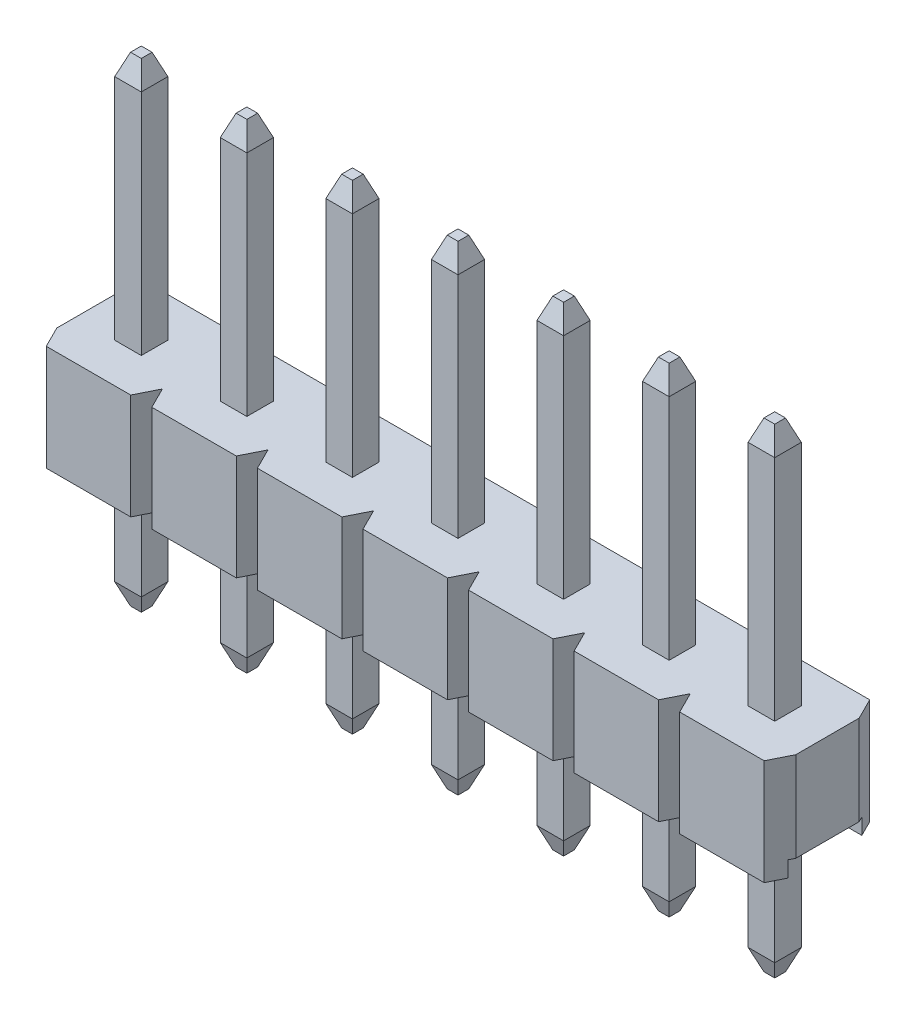
from build123d import *
from OCP.BRepFilletAPI import BRepFilletAPI_MakeChamfer

# Parameters (mm, degrees)
SKETCH1_W                     = 2.54
SKETCH1_H                     = 2.54
MAIN_BODY_DEPTH               = 2.54
SKETCH3_W                     = 1.778
SKETCH3_H                     = 0.381
CUT_EXTRUDE1_DEPTH            = 5.399409051
CUT_EXTRUDE2_DEPTH            = 5.399409051
BODY_PATTERN_COUNT            = 7
BODY_PATTERN_PITCH            = 2.54
PIN_START                     = -5.54
SKETCH2_W                     = 0.64
SKETCH2_H                     = 0.64
PIN_DEPTH                     = 11.54
CHAMFER1_SIZE                 = 0.508
CHAMFER1_SIZE2                = 0.1905
CHAMFER2_SIZE                 = 0.1905
CHAMFER2_SIZE2                = 0.508
PIN_PATTERN_COUNT             = 7
PIN_PATTERN_PITCH             = 2.54
CHAMFER1_OF_PIN_PATTERN_SIZE  = 0.508
CHAMFER1_OF_PIN_PATTERN_SIZE2 = 0.1905
CHAMFER2_OF_PIN_PATTERN_SIZE2 = 0.1905
CHAMFER2_OF_PIN_PATTERN_SIZE  = 0.508


with BuildPart() as part:
    # Sketch1 → Main Body (new body)
    with BuildSketch(Plane(origin=(0, 0, 0), x_dir=(1, 0, 0), z_dir=(0, 1, 0))):
        with Locations((1.27, 1.27)):
            Rectangle(SKETCH1_W, SKETCH1_H)
    main_body = extrude(amount=MAIN_BODY_DEPTH)

    # Sketch3 → Cut-Extrude1 (cut, through all)
    with BuildSketch(Plane.ZY):
        with Locations((-1.27, 0.1905)):
            Rectangle(SKETCH3_W, SKETCH3_H)
    cut_extrude1 = extrude(amount=-CUT_EXTRUDE1_DEPTH, mode=Mode.SUBTRACT)

    # Sketch4 → Cut-Extrude2 (cut, through all)
    with BuildSketch(Plane(origin=(0, 2.54, 0), x_dir=(1, 0, 0), z_dir=(0, 1, 0))):
        Polygon((0.254, 2.54), (0, 2.54), (0, 2.032), align=None)
        Polygon((2.54, 2.54), (2.286, 2.54), (2.54, 2.032), align=None)
        Polygon((0.254, 0), (0, 0.508), (0, 0), align=None)
        Polygon((2.54, 0), (2.286, 0), (2.54, 0.508), align=None)
    cut_extrude2 = extrude(amount=-CUT_EXTRUDE2_DEPTH, mode=Mode.SUBTRACT)

    # Body Pattern: Main Body, Cut-Extrude1, Cut-Extrude2 ×7
    with Locations(*[(-i * BODY_PATTERN_PITCH, 0, 0) for i in range(1, BODY_PATTERN_COUNT)]):
        add(main_body)
        add(cut_extrude1, mode=Mode.SUBTRACT)
        add(cut_extrude2, mode=Mode.SUBTRACT)

    # Sketch2 → Pin (add)
    with BuildSketch(Plane(origin=(0, 2.54, 0), x_dir=(1, 0, 0), z_dir=(0, 1, 0)).offset(PIN_START)):
        with Locations((1.27, 1.27)):
            Rectangle(SKETCH2_W, SKETCH2_H)
    pin = extrude(amount=PIN_DEPTH)

    # Chamfer1: one chamfer whose edges measure the first distance from different faces: ONE call of the kernel's chamfer builder (chamfer() names one face for all edges)
    chamfer1_edges_1 = [part.edges().sort_by_distance(p)[0] for p in [
        (0.95, 8.54, -1.27),
    ]]
    chamfer1_side_1 = [part.faces().sort_by_distance(p)[0] for p in [
        (0.95, 5.54, -1.27),
    ]]
    chamfer1_edges_2 = [part.edges().sort_by_distance(p)[0] for p in [
        (1.27, 8.54, -0.95),
    ]]
    chamfer1_side_2 = [part.faces().sort_by_distance(p)[0] for p in [
        (1.27, 5.54, -0.95),
    ]]
    chamfer1_edges_3 = [part.edges().sort_by_distance(p)[0] for p in [
        (1.59, 8.54, -1.27),
    ]]
    chamfer1_side_3 = [part.faces().sort_by_distance(p)[0] for p in [
        (1.59, 5.54, -1.27),
    ]]
    chamfer1_edges_4 = [part.edges().sort_by_distance(p)[0] for p in [
        (1.27, 8.54, -1.59),
    ]]
    chamfer1_side_4 = [part.faces().sort_by_distance(p)[0] for p in [
        (1.27, 5.54, -1.59),
    ]]
    chamfer1 = BRepFilletAPI_MakeChamfer(part.part.solid().wrapped)
    for e in chamfer1_edges_1:
        chamfer1.Add(CHAMFER1_SIZE, CHAMFER1_SIZE2, e.wrapped, chamfer1_side_1[0].wrapped)  # the first distance lies on this face
    for e in chamfer1_edges_2:
        chamfer1.Add(CHAMFER1_SIZE, CHAMFER1_SIZE2, e.wrapped, chamfer1_side_2[0].wrapped)  # the first distance lies on this face
    for e in chamfer1_edges_3:
        chamfer1.Add(CHAMFER1_SIZE, CHAMFER1_SIZE2, e.wrapped, chamfer1_side_3[0].wrapped)  # the first distance lies on this face
    for e in chamfer1_edges_4:
        chamfer1.Add(CHAMFER1_SIZE, CHAMFER1_SIZE2, e.wrapped, chamfer1_side_4[0].wrapped)  # the first distance lies on this face
    add(Compound.cast(chamfer1.Shape()), mode=Mode.REPLACE)

    # Chamfer2
    chamfer2_edges = [part.edges().sort_by_distance(p)[0] for p in [
        (1.27, -3, -0.95),
        (1.59, -3, -1.27),
        (1.27, -3, -1.59),
        (0.95, -3, -1.27),
    ]]
    chamfer2_side = [part.faces().sort_by_distance(p)[0] for p in [
        (1.27, -3, -1.27),
    ]]
    chamfer(chamfer2_edges, length=CHAMFER2_SIZE, length2=CHAMFER2_SIZE2, reference=chamfer2_side[0])

    # Pin Pattern: Pin ×7
    with Locations(*[(-i * PIN_PATTERN_PITCH, 0, 0) for i in range(1, PIN_PATTERN_COUNT)]):
        add(pin)

    # Chamfer1 of Pin Pattern: one chamfer whose edges measure the first distance from different faces: ONE call of the kernel's chamfer builder (chamfer() names one face for all edges)
    chamfer1_of_pin_pattern_edges_1 = [part.edges().sort_by_distance(p)[0] for p in [
        (-1.59, 8.54, -1.27),
    ]]
    chamfer1_of_pin_pattern_side_1 = [part.faces().sort_by_distance(p)[0] for p in [
        (-1.59, 5.54, -1.27),
    ]]
    chamfer1_of_pin_pattern_edges_2 = [part.edges().sort_by_distance(p)[0] for p in [
        (-1.27, 8.54, -0.95),
    ]]
    chamfer1_of_pin_pattern_side_2 = [part.faces().sort_by_distance(p)[0] for p in [
        (-1.27, 5.54, -0.95),
    ]]
    chamfer1_of_pin_pattern_edges_3 = [part.edges().sort_by_distance(p)[0] for p in [
        (-0.95, 8.54, -1.27),
    ]]
    chamfer1_of_pin_pattern_side_3 = [part.faces().sort_by_distance(p)[0] for p in [
        (-0.95, 5.54, -1.27),
    ]]
    chamfer1_of_pin_pattern_edges_4 = [part.edges().sort_by_distance(p)[0] for p in [
        (-1.27, 8.54, -1.59),
    ]]
    chamfer1_of_pin_pattern_side_4 = [part.faces().sort_by_distance(p)[0] for p in [
        (-1.27, 5.54, -1.59),
    ]]
    chamfer1_of_pin_pattern_edges_5 = [part.edges().sort_by_distance(p)[0] for p in [
        (-4.13, 8.54, -1.27),
    ]]
    chamfer1_of_pin_pattern_side_5 = [part.faces().sort_by_distance(p)[0] for p in [
        (-4.13, 5.54, -1.27),
    ]]
    chamfer1_of_pin_pattern_edges_6 = [part.edges().sort_by_distance(p)[0] for p in [
        (-3.81, 8.54, -0.95),
    ]]
    chamfer1_of_pin_pattern_side_6 = [part.faces().sort_by_distance(p)[0] for p in [
        (-3.81, 5.54, -0.95),
    ]]
    chamfer1_of_pin_pattern_edges_7 = [part.edges().sort_by_distance(p)[0] for p in [
        (-3.49, 8.54, -1.27),
    ]]
    chamfer1_of_pin_pattern_side_7 = [part.faces().sort_by_distance(p)[0] for p in [
        (-3.49, 5.54, -1.27),
    ]]
    chamfer1_of_pin_pattern_edges_8 = [part.edges().sort_by_distance(p)[0] for p in [
        (-3.81, 8.54, -1.59),
    ]]
    chamfer1_of_pin_pattern_side_8 = [part.faces().sort_by_distance(p)[0] for p in [
        (-3.81, 5.54, -1.59),
    ]]
    chamfer1_of_pin_pattern_edges_9 = [part.edges().sort_by_distance(p)[0] for p in [
        (-6.67, 8.54, -1.27),
    ]]
    chamfer1_of_pin_pattern_side_9 = [part.faces().sort_by_distance(p)[0] for p in [
        (-6.67, 5.54, -1.27),
    ]]
    chamfer1_of_pin_pattern_edges_10 = [part.edges().sort_by_distance(p)[0] for p in [
        (-6.35, 8.54, -0.95),
    ]]
    chamfer1_of_pin_pattern_side_10 = [part.faces().sort_by_distance(p)[0] for p in [
        (-6.35, 5.54, -0.95),
    ]]
    chamfer1_of_pin_pattern_edges_11 = [part.edges().sort_by_distance(p)[0] for p in [
        (-6.03, 8.54, -1.27),
    ]]
    chamfer1_of_pin_pattern_side_11 = [part.faces().sort_by_distance(p)[0] for p in [
        (-6.03, 5.54, -1.27),
    ]]
    chamfer1_of_pin_pattern_edges_12 = [part.edges().sort_by_distance(p)[0] for p in [
        (-6.35, 8.54, -1.59),
    ]]
    chamfer1_of_pin_pattern_side_12 = [part.faces().sort_by_distance(p)[0] for p in [
        (-6.35, 5.54, -1.59),
    ]]
    chamfer1_of_pin_pattern_edges_13 = [part.edges().sort_by_distance(p)[0] for p in [
        (-9.21, 8.54, -1.27),
    ]]
    chamfer1_of_pin_pattern_side_13 = [part.faces().sort_by_distance(p)[0] for p in [
        (-9.21, 5.54, -1.27),
    ]]
    chamfer1_of_pin_pattern_edges_14 = [part.edges().sort_by_distance(p)[0] for p in [
        (-8.89, 8.54, -0.95),
    ]]
    chamfer1_of_pin_pattern_side_14 = [part.faces().sort_by_distance(p)[0] for p in [
        (-8.89, 5.54, -0.95),
    ]]
    chamfer1_of_pin_pattern_edges_15 = [part.edges().sort_by_distance(p)[0] for p in [
        (-8.57, 8.54, -1.27),
    ]]
    chamfer1_of_pin_pattern_side_15 = [part.faces().sort_by_distance(p)[0] for p in [
        (-8.57, 5.54, -1.27),
    ]]
    chamfer1_of_pin_pattern_edges_16 = [part.edges().sort_by_distance(p)[0] for p in [
        (-8.89, 8.54, -1.59),
    ]]
    chamfer1_of_pin_pattern_side_16 = [part.faces().sort_by_distance(p)[0] for p in [
        (-8.89, 5.54, -1.59),
    ]]
    chamfer1_of_pin_pattern_edges_17 = [part.edges().sort_by_distance(p)[0] for p in [
        (-11.75, 8.54, -1.27),
    ]]
    chamfer1_of_pin_pattern_side_17 = [part.faces().sort_by_distance(p)[0] for p in [
        (-11.75, 5.54, -1.27),
    ]]
    chamfer1_of_pin_pattern_edges_18 = [part.edges().sort_by_distance(p)[0] for p in [
        (-11.43, 8.54, -0.95),
    ]]
    chamfer1_of_pin_pattern_side_18 = [part.faces().sort_by_distance(p)[0] for p in [
        (-11.43, 5.54, -0.95),
    ]]
    chamfer1_of_pin_pattern_edges_19 = [part.edges().sort_by_distance(p)[0] for p in [
        (-11.11, 8.54, -1.27),
    ]]
    chamfer1_of_pin_pattern_side_19 = [part.faces().sort_by_distance(p)[0] for p in [
        (-11.11, 5.54, -1.27),
    ]]
    chamfer1_of_pin_pattern_edges_20 = [part.edges().sort_by_distance(p)[0] for p in [
        (-11.43, 8.54, -1.59),
    ]]
    chamfer1_of_pin_pattern_side_20 = [part.faces().sort_by_distance(p)[0] for p in [
        (-11.43, 5.54, -1.59),
    ]]
    chamfer1_of_pin_pattern_edges_21 = [part.edges().sort_by_distance(p)[0] for p in [
        (-14.29, 8.54, -1.27),
    ]]
    chamfer1_of_pin_pattern_side_21 = [part.faces().sort_by_distance(p)[0] for p in [
        (-14.29, 5.54, -1.27),
    ]]
    chamfer1_of_pin_pattern_edges_22 = [part.edges().sort_by_distance(p)[0] for p in [
        (-13.97, 8.54, -0.95),
    ]]
    chamfer1_of_pin_pattern_side_22 = [part.faces().sort_by_distance(p)[0] for p in [
        (-13.97, 5.54, -0.95),
    ]]
    chamfer1_of_pin_pattern_edges_23 = [part.edges().sort_by_distance(p)[0] for p in [
        (-13.65, 8.54, -1.27),
    ]]
    chamfer1_of_pin_pattern_side_23 = [part.faces().sort_by_distance(p)[0] for p in [
        (-13.65, 5.54, -1.27),
    ]]
    chamfer1_of_pin_pattern_edges_24 = [part.edges().sort_by_distance(p)[0] for p in [
        (-13.97, 8.54, -1.59),
    ]]
    chamfer1_of_pin_pattern_side_24 = [part.faces().sort_by_distance(p)[0] for p in [
        (-13.97, 5.54, -1.59),
    ]]
    chamfer1_of_pin_pattern = BRepFilletAPI_MakeChamfer(part.part.solid().wrapped)
    for e in chamfer1_of_pin_pattern_edges_1:
        chamfer1_of_pin_pattern.Add(CHAMFER1_OF_PIN_PATTERN_SIZE, CHAMFER1_OF_PIN_PATTERN_SIZE2, e.wrapped, chamfer1_of_pin_pattern_side_1[0].wrapped)  # the first distance lies on this face
    for e in chamfer1_of_pin_pattern_edges_2:
        chamfer1_of_pin_pattern.Add(CHAMFER1_OF_PIN_PATTERN_SIZE, CHAMFER1_OF_PIN_PATTERN_SIZE2, e.wrapped, chamfer1_of_pin_pattern_side_2[0].wrapped)  # the first distance lies on this face
    for e in chamfer1_of_pin_pattern_edges_3:
        chamfer1_of_pin_pattern.Add(CHAMFER1_OF_PIN_PATTERN_SIZE, CHAMFER1_OF_PIN_PATTERN_SIZE2, e.wrapped, chamfer1_of_pin_pattern_side_3[0].wrapped)  # the first distance lies on this face
    for e in chamfer1_of_pin_pattern_edges_4:
        chamfer1_of_pin_pattern.Add(CHAMFER1_OF_PIN_PATTERN_SIZE, CHAMFER1_OF_PIN_PATTERN_SIZE2, e.wrapped, chamfer1_of_pin_pattern_side_4[0].wrapped)  # the first distance lies on this face
    for e in chamfer1_of_pin_pattern_edges_5:
        chamfer1_of_pin_pattern.Add(CHAMFER1_OF_PIN_PATTERN_SIZE, CHAMFER1_OF_PIN_PATTERN_SIZE2, e.wrapped, chamfer1_of_pin_pattern_side_5[0].wrapped)  # the first distance lies on this face
    for e in chamfer1_of_pin_pattern_edges_6:
        chamfer1_of_pin_pattern.Add(CHAMFER1_OF_PIN_PATTERN_SIZE, CHAMFER1_OF_PIN_PATTERN_SIZE2, e.wrapped, chamfer1_of_pin_pattern_side_6[0].wrapped)  # the first distance lies on this face
    for e in chamfer1_of_pin_pattern_edges_7:
        chamfer1_of_pin_pattern.Add(CHAMFER1_OF_PIN_PATTERN_SIZE, CHAMFER1_OF_PIN_PATTERN_SIZE2, e.wrapped, chamfer1_of_pin_pattern_side_7[0].wrapped)  # the first distance lies on this face
    for e in chamfer1_of_pin_pattern_edges_8:
        chamfer1_of_pin_pattern.Add(CHAMFER1_OF_PIN_PATTERN_SIZE, CHAMFER1_OF_PIN_PATTERN_SIZE2, e.wrapped, chamfer1_of_pin_pattern_side_8[0].wrapped)  # the first distance lies on this face
    for e in chamfer1_of_pin_pattern_edges_9:
        chamfer1_of_pin_pattern.Add(CHAMFER1_OF_PIN_PATTERN_SIZE, CHAMFER1_OF_PIN_PATTERN_SIZE2, e.wrapped, chamfer1_of_pin_pattern_side_9[0].wrapped)  # the first distance lies on this face
    for e in chamfer1_of_pin_pattern_edges_10:
        chamfer1_of_pin_pattern.Add(CHAMFER1_OF_PIN_PATTERN_SIZE, CHAMFER1_OF_PIN_PATTERN_SIZE2, e.wrapped, chamfer1_of_pin_pattern_side_10[0].wrapped)  # the first distance lies on this face
    for e in chamfer1_of_pin_pattern_edges_11:
        chamfer1_of_pin_pattern.Add(CHAMFER1_OF_PIN_PATTERN_SIZE, CHAMFER1_OF_PIN_PATTERN_SIZE2, e.wrapped, chamfer1_of_pin_pattern_side_11[0].wrapped)  # the first distance lies on this face
    for e in chamfer1_of_pin_pattern_edges_12:
        chamfer1_of_pin_pattern.Add(CHAMFER1_OF_PIN_PATTERN_SIZE, CHAMFER1_OF_PIN_PATTERN_SIZE2, e.wrapped, chamfer1_of_pin_pattern_side_12[0].wrapped)  # the first distance lies on this face
    for e in chamfer1_of_pin_pattern_edges_13:
        chamfer1_of_pin_pattern.Add(CHAMFER1_OF_PIN_PATTERN_SIZE, CHAMFER1_OF_PIN_PATTERN_SIZE2, e.wrapped, chamfer1_of_pin_pattern_side_13[0].wrapped)  # the first distance lies on this face
    for e in chamfer1_of_pin_pattern_edges_14:
        chamfer1_of_pin_pattern.Add(CHAMFER1_OF_PIN_PATTERN_SIZE, CHAMFER1_OF_PIN_PATTERN_SIZE2, e.wrapped, chamfer1_of_pin_pattern_side_14[0].wrapped)  # the first distance lies on this face
    for e in chamfer1_of_pin_pattern_edges_15:
        chamfer1_of_pin_pattern.Add(CHAMFER1_OF_PIN_PATTERN_SIZE, CHAMFER1_OF_PIN_PATTERN_SIZE2, e.wrapped, chamfer1_of_pin_pattern_side_15[0].wrapped)  # the first distance lies on this face
    for e in chamfer1_of_pin_pattern_edges_16:
        chamfer1_of_pin_pattern.Add(CHAMFER1_OF_PIN_PATTERN_SIZE, CHAMFER1_OF_PIN_PATTERN_SIZE2, e.wrapped, chamfer1_of_pin_pattern_side_16[0].wrapped)  # the first distance lies on this face
    for e in chamfer1_of_pin_pattern_edges_17:
        chamfer1_of_pin_pattern.Add(CHAMFER1_OF_PIN_PATTERN_SIZE, CHAMFER1_OF_PIN_PATTERN_SIZE2, e.wrapped, chamfer1_of_pin_pattern_side_17[0].wrapped)  # the first distance lies on this face
    for e in chamfer1_of_pin_pattern_edges_18:
        chamfer1_of_pin_pattern.Add(CHAMFER1_OF_PIN_PATTERN_SIZE, CHAMFER1_OF_PIN_PATTERN_SIZE2, e.wrapped, chamfer1_of_pin_pattern_side_18[0].wrapped)  # the first distance lies on this face
    for e in chamfer1_of_pin_pattern_edges_19:
        chamfer1_of_pin_pattern.Add(CHAMFER1_OF_PIN_PATTERN_SIZE, CHAMFER1_OF_PIN_PATTERN_SIZE2, e.wrapped, chamfer1_of_pin_pattern_side_19[0].wrapped)  # the first distance lies on this face
    for e in chamfer1_of_pin_pattern_edges_20:
        chamfer1_of_pin_pattern.Add(CHAMFER1_OF_PIN_PATTERN_SIZE, CHAMFER1_OF_PIN_PATTERN_SIZE2, e.wrapped, chamfer1_of_pin_pattern_side_20[0].wrapped)  # the first distance lies on this face
    for e in chamfer1_of_pin_pattern_edges_21:
        chamfer1_of_pin_pattern.Add(CHAMFER1_OF_PIN_PATTERN_SIZE, CHAMFER1_OF_PIN_PATTERN_SIZE2, e.wrapped, chamfer1_of_pin_pattern_side_21[0].wrapped)  # the first distance lies on this face
    for e in chamfer1_of_pin_pattern_edges_22:
        chamfer1_of_pin_pattern.Add(CHAMFER1_OF_PIN_PATTERN_SIZE, CHAMFER1_OF_PIN_PATTERN_SIZE2, e.wrapped, chamfer1_of_pin_pattern_side_22[0].wrapped)  # the first distance lies on this face
    for e in chamfer1_of_pin_pattern_edges_23:
        chamfer1_of_pin_pattern.Add(CHAMFER1_OF_PIN_PATTERN_SIZE, CHAMFER1_OF_PIN_PATTERN_SIZE2, e.wrapped, chamfer1_of_pin_pattern_side_23[0].wrapped)  # the first distance lies on this face
    for e in chamfer1_of_pin_pattern_edges_24:
        chamfer1_of_pin_pattern.Add(CHAMFER1_OF_PIN_PATTERN_SIZE, CHAMFER1_OF_PIN_PATTERN_SIZE2, e.wrapped, chamfer1_of_pin_pattern_side_24[0].wrapped)  # the first distance lies on this face
    add(Compound.cast(chamfer1_of_pin_pattern.Shape()), mode=Mode.REPLACE)

    # Chamfer2 of Pin Pattern
    chamfer2_of_pin_pattern_edges = [part.edges().sort_by_distance(p)[0] for p in [
        (-1.27, -3, -0.95),
        (-0.95, -3, -1.27),
        (-1.27, -3, -1.59),
        (-1.59, -3, -1.27),
        (-3.81, -3, -0.95),
        (-3.49, -3, -1.27),
        (-3.81, -3, -1.59),
        (-4.13, -3, -1.27),
        (-6.35, -3, -0.95),
        (-6.03, -3, -1.27),
        (-6.35, -3, -1.59),
        (-6.67, -3, -1.27),
        (-8.89, -3, -0.95),
        (-8.57, -3, -1.27),
        (-8.89, -3, -1.59),
        (-9.21, -3, -1.27),
        (-11.43, -3, -0.95),
        (-11.11, -3, -1.27),
        (-11.43, -3, -1.59),
        (-11.75, -3, -1.27),
        (-13.97, -3, -0.95),
        (-13.65, -3, -1.27),
        (-13.97, -3, -1.59),
        (-14.29, -3, -1.27),
    ]]
    chamfer(chamfer2_of_pin_pattern_edges, length=CHAMFER2_OF_PIN_PATTERN_SIZE, length2=CHAMFER2_OF_PIN_PATTERN_SIZE2)


solid = part.part
